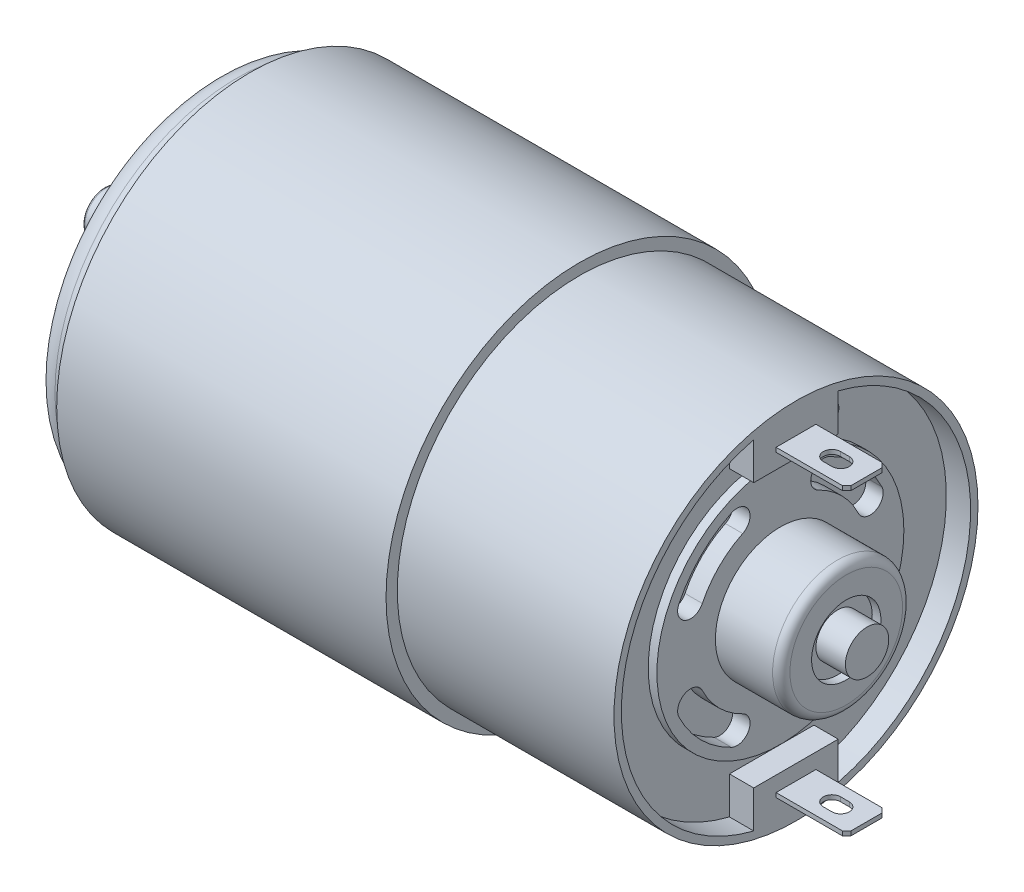
from build123d import *

# Parameters (mm, degrees)
SKETCH1_W                      = 38
SKETCH1_H                      = 22.3
SKETCH2_R                      = 21
BOSS_EXTRUDE1_DEPTH            = 25
SKETCH3_W                      = 4.6
SKETCH3_H                      = 0.5
BOSS_EXTRUDE2_DEPTH            = 8.15
CUT_EXTRUDE1_DEPTH             = 40.8
SKETCH5_W                      = 4.6
SKETCH5_H                      = 0.5
BOSS_EXTRUDE3_DEPTH            = 8.15
CUT_EXTRUDE2_REACH             = 41.8
CUT_EXTRUDE3_DEPTH             = 2.8
SKETCH8_R                      = 14.25
BOSS_EXTRUDE4_DEPTH            = 1
CUT_EXTRUDE4_DEPTH             = 2
CUT_EXTRUDE5_DEPTH             = 2
CUT_EXTRUDE6_DEPTH             = 2
CUT_EXTRUDE7_DEPTH             = 2
SKETCH13_R                     = 21
BOSS_EXTRUDE5_DEPTH            = 4
CUT_EXTRUDE8_DEPTH             = 10
CUT_EXTRUDE9_DEPTH             = 10
CUT_EXTRUDE10_DEPTH            = 10
CUT_EXTRUDE11_DEPTH            = 10
SKETCH18_R                     = 7.5
BOSS_EXTRUDE6_DEPTH            = 7.6
F_8_0_8_DIAMETER_HOLE1_D       = 8
F_8_0_8_DIAMETER_HOLE1_DEPTH   = 1
SKETCH21_R                     = 8.65
BOSS_EXTRUDE7_DEPTH            = 5
M12_CLEARANCE_HOLE1_D          = 13.25
M12_CLEARANCE_HOLE1_DEPTH      = 1
SKETCH25_W                     = 3.4
SKETCH25_H                     = 2.5
F_2_5_2_5_DIAMETER_HOLE1_D     = 2.5
F_2_5_2_5_DIAMETER_HOLE1_DEPTH = 0.1
F_3_3_3_3_DIAMETER_HOLE1_D     = 3.3
F_3_3_3_3_DIAMETER_HOLE1_DEPTH = 11.5
F_3_3_3_3_DIAMETER_HOLE1_TIP   = 0.991420021
CHAMFER1_SIZE                  = 0.5
FILLET1_R                      = 0.25
FILLET2_R                      = 0.75
FILLET3_R                      = 1
FILLET4_R                      = 2.5


with BuildPart() as part:
    # Sketch1 → Revolve1 (revolve)
    with BuildSketch(Plane.XY):
        with Locations((23, 11.15)):
            Rectangle(SKETCH1_W, SKETCH1_H)
    revolve(axis=Axis((4, 0, 0), (1, 0, 0)))

    # Sketch2 → Boss-Extrude1 (add)
    with BuildSketch(Plane(origin=(42, 0, 0), x_dir=(0, 0, -1), z_dir=(1, 0, 0))):
        Circle(SKETCH2_R)
    extrude(amount=BOSS_EXTRUDE1_DEPTH)

    # Sketch3 → Boss-Extrude2 (add)
    with BuildSketch(Plane(origin=(67, 0, 0), x_dir=(0, 0, -1), z_dir=(1, 0, 0))):
        with Locations((0, 17.25)):
            Rectangle(SKETCH3_W, SKETCH3_H)
    extrude(amount=BOSS_EXTRUDE2_DEPTH)

    # Sketch4 → Cut-Extrude1 (cut, through all)
    with BuildSketch(Plane(origin=(0, 17.5, 0), x_dir=(-1, 0, 0), z_dir=(0, 1, 0))):
        with BuildLine():
            Line((-72.15, -1), (-71.15, -1))
            ThreePointArc((-71.15, -1), (-70.15, 0), (-71.15, 1))
            Line((-71.15, 1), (-72.15, 1))
            ThreePointArc((-72.15, 1), (-73.15, 0), (-72.15, -1))
        make_face()
    extrude(amount=-CUT_EXTRUDE1_DEPTH, mode=Mode.SUBTRACT)

    # Sketch5 → Boss-Extrude3 (add)
    with BuildSketch(Plane(origin=(67, 0, 0), x_dir=(0, 0, -1), z_dir=(1, 0, 0))):
        with Locations((0, -17.25)):
            Rectangle(SKETCH5_W, SKETCH5_H)
    extrude(amount=BOSS_EXTRUDE3_DEPTH)

    # Sketch6 → Cut-Extrude2 (cut, up to next)
    with BuildSketch(Plane.XZ.offset(17.5), mode=Mode.PRIVATE) as cut_extrude2_sk1:
        with BuildLine():
            Line((72.15, 1), (71.15, 1))
            ThreePointArc((71.15, 1), (70.15, 0), (71.15, -1))
            Line((71.15, -1), (72.15, -1))
            ThreePointArc((72.15, -1), (73.15, 0), (72.15, 1))
        make_face()
    cut_extrude2_tool1 = extrude(cut_extrude2_sk1.sketch, amount=-CUT_EXTRUDE2_REACH, mode=Mode.PRIVATE) & part.part
    add(cut_extrude2_tool1.solids().sort_by_distance((71.65, -17.5, 0))[0], mode=Mode.SUBTRACT)

    # Sketch7 → Cut-Extrude3 (cut)
    with BuildSketch(Plane(origin=(67, 0, 0), x_dir=(0, 0, -1), z_dir=(1, 0, 0))):
        with BuildLine():
            Line((4.875, 19.551390616), (4.875, 15.25))
            Line((4.875, 15.25), (-4.875, 15.25))
            Line((-4.875, 15.25), (-4.875, 19.551390616))
            ThreePointArc((-4.875, 19.551390616), (-20.15, 0), (-4.875, -19.551390616))
            Line((-4.875, -19.551390616), (-4.875, -15.25))
            Line((-4.875, -15.25), (4.875, -15.25))
            Line((4.875, -15.25), (4.875, -19.551390616))
            ThreePointArc((4.875, -19.551390616), (20.15, 0), (4.875, 19.551390616))
        make_face()
    extrude(amount=-CUT_EXTRUDE3_DEPTH, mode=Mode.SUBTRACT)

    # Sketch8 → Boss-Extrude4 (add)
    with BuildSketch(Plane(origin=(64.2, 0, 0), x_dir=(0, 0, -1), z_dir=(1, 0, 0))):
        Circle(SKETCH8_R)
    extrude(amount=BOSS_EXTRUDE4_DEPTH)

    # Sketch9 → Cut-Extrude4 (cut)
    with BuildSketch(Plane(origin=(65.2, 0, 0), x_dir=(0, 0, -1), z_dir=(1, 0, 0))):
        with BuildLine():
            ThreePointArc((-5.652173913, 11.706960752), (-9.192388155, 9.192388155), (-11.706960752, 5.652173913))
            ThreePointArc((-11.706960752, 5.652173913), (-11.008331502, 3.649196836), (-9.005354425, 4.347826087))
            ThreePointArc((-9.005354425, 4.347826087), (-7.071067812, 7.071067812), (-4.347826087, 9.005354425))
            ThreePointArc((-4.347826087, 9.005354425), (-3.649196836, 11.008331502), (-5.652173913, 11.706960752))
        make_face()
    extrude(amount=-CUT_EXTRUDE4_DEPTH, mode=Mode.SUBTRACT)

    # Sketch10 → Cut-Extrude5 (cut)
    with BuildSketch(Plane(origin=(65.2, 0, 0), x_dir=(0, 0, -1), z_dir=(1, 0, 0))):
        with BuildLine():
            ThreePointArc((11.706960752, 5.652173913), (9.192388155, 9.192388155), (5.652173913, 11.706960752))
            ThreePointArc((5.652173913, 11.706960752), (3.649196836, 11.008331502), (4.347826087, 9.005354425))
            ThreePointArc((4.347826087, 9.005354425), (7.071067812, 7.071067812), (9.005354425, 4.347826087))
            ThreePointArc((9.005354425, 4.347826087), (11.008331502, 3.649196836), (11.706960752, 5.652173913))
        make_face()
    extrude(amount=-CUT_EXTRUDE5_DEPTH, mode=Mode.SUBTRACT)

    # Sketch11 → Cut-Extrude6 (cut)
    with BuildSketch(Plane(origin=(65.2, 0, 0), x_dir=(0, 0, -1), z_dir=(1, 0, 0))):
        with BuildLine():
            ThreePointArc((5.652173913, -11.706960752), (9.192388155, -9.192388155), (11.706960752, -5.652173913))
            ThreePointArc((11.706960752, -5.652173913), (11.008331502, -3.649196836), (9.005354425, -4.347826087))
            ThreePointArc((9.005354425, -4.347826087), (7.071067812, -7.071067812), (4.347826087, -9.005354425))
            ThreePointArc((4.347826087, -9.005354425), (3.649196836, -11.008331502), (5.652173913, -11.706960752))
        make_face()
    extrude(amount=-CUT_EXTRUDE6_DEPTH, mode=Mode.SUBTRACT)

    # Sketch12 → Cut-Extrude7 (cut)
    with BuildSketch(Plane(origin=(65.2, 0, 0), x_dir=(0, 0, -1), z_dir=(1, 0, 0))):
        with BuildLine():
            ThreePointArc((-11.706960752, -5.652173913), (-9.192388155, -9.192388155), (-5.652173913, -11.706960752))
            ThreePointArc((-5.652173913, -11.706960752), (-3.649196836, -11.008331502), (-4.347826087, -9.005354425))
            ThreePointArc((-4.347826087, -9.005354425), (-7.071067812, -7.071067812), (-9.005354425, -4.347826087))
            ThreePointArc((-9.005354425, -4.347826087), (-11.008331502, -3.649196836), (-11.706960752, -5.652173913))
        make_face()
    extrude(amount=-CUT_EXTRUDE7_DEPTH, mode=Mode.SUBTRACT)

    # Sketch13 → Boss-Extrude5 (add)
    with BuildSketch(Plane.ZY.offset(-4)):
        Circle(SKETCH13_R)
    extrude(amount=BOSS_EXTRUDE5_DEPTH)

    # Sketch14 → Cut-Extrude8 (cut)
    with BuildSketch(Plane.ZY):
        with BuildLine():
            Line((6.761892188, 14.500924593), (4.775586358, 10.241277994))
            ThreePointArc((4.775586358, 10.241277994), (7.990306627, 7.990306627), (10.241277994, 4.775586358))
            Line((10.241277994, 4.775586358), (14.500924593, 6.761892188))
            ThreePointArc((14.500924593, 6.761892188), (11.313708499, 11.313708499), (6.761892188, 14.500924593))
        make_face()
    extrude(amount=-CUT_EXTRUDE8_DEPTH, mode=Mode.SUBTRACT)

    # Sketch15 → Cut-Extrude9 (cut)
    with BuildSketch(Plane.ZY):
        with BuildLine():
            Line((-6.761892188, -14.500924593), (-4.775586358, -10.241277994))
            ThreePointArc((-4.775586358, -10.241277994), (-7.990306627, -7.990306627), (-10.241277994, -4.775586358))
            Line((-10.241277994, -4.775586358), (-14.500924593, -6.761892188))
            ThreePointArc((-14.500924593, -6.761892188), (-11.313708499, -11.313708499), (-6.761892188, -14.500924593))
        make_face()
    extrude(amount=-CUT_EXTRUDE9_DEPTH, mode=Mode.SUBTRACT)

    # Sketch16 → Cut-Extrude10 (cut)
    with BuildSketch(Plane.ZY):
        with BuildLine():
            Line((-14.500924593, 6.761892188), (-10.241277994, 4.775586358))
            ThreePointArc((-10.241277994, 4.775586358), (-7.990306627, 7.990306627), (-4.775586358, 10.241277994))
            Line((-4.775586358, 10.241277994), (-6.761892188, 14.500924593))
            ThreePointArc((-6.761892188, 14.500924593), (-11.313708499, 11.313708499), (-14.500924593, 6.761892188))
        make_face()
    extrude(amount=-CUT_EXTRUDE10_DEPTH, mode=Mode.SUBTRACT)

    # Sketch17 → Cut-Extrude11 (cut)
    with BuildSketch(Plane.ZY):
        with BuildLine():
            Line((14.500924593, -6.761892188), (10.241277994, -4.775586358))
            ThreePointArc((10.241277994, -4.775586358), (7.990306627, -7.990306627), (4.775586358, -10.241277994))
            Line((4.775586358, -10.241277994), (6.761892188, -14.500924593))
            ThreePointArc((6.761892188, -14.500924593), (11.313708499, -11.313708499), (14.500924593, -6.761892188))
        make_face()
    extrude(amount=-CUT_EXTRUDE11_DEPTH, mode=Mode.SUBTRACT)

    # Sketch18 → Boss-Extrude6 (add)
    with BuildSketch(Plane(origin=(65.2, 0, 0), x_dir=(0, 0, -1), z_dir=(1, 0, 0))):
        Circle(SKETCH18_R)
    extrude(amount=BOSS_EXTRUDE6_DEPTH)

    # Ø8.0 (8) Diameter Hole1
    with Locations(Plane(origin=(72.8, 0, 0), x_dir=(0, 0, -1), z_dir=(1, 0, 0))):
        with Locations((0, 0)):
            Hole(F_8_0_8_DIAMETER_HOLE1_D / 2, depth=F_8_0_8_DIAMETER_HOLE1_DEPTH)

    # Sketch21 → Boss-Extrude7 (add)
    with BuildSketch(Plane.ZY):
        Circle(SKETCH21_R)
    extrude(amount=BOSS_EXTRUDE7_DEPTH)

    # M12 Clearance Hole1
    with Locations(Plane.ZY.offset(5)):
        with Locations((0, 0)):
            Hole(M12_CLEARANCE_HOLE1_D / 2, depth=M12_CLEARANCE_HOLE1_DEPTH)

    # Sketch24 → Revolve2 (revolve)
    with BuildSketch(Plane(origin=(0, 0, 0), x_dir=(-1, 0, 0), z_dir=(0, 0, -1))):
        Polygon((4, 3.75), (4, 0), (12.8, 0), (12.8, 2.5), (5, 2.5), (5, 3.75), align=None)
    revolve(axis=Axis((-4, 0, 0), (-1, 0, 0)))

    # Sketch25 → Revolve3 (revolve)
    with BuildSketch(Plane(origin=(0, 0, 0), x_dir=(-1, 0, 0), z_dir=(0, 0, -1))):
        with Locations((-73.5, 1.25)):
            Rectangle(SKETCH25_W, SKETCH25_H)
    revolve(axis=Axis((75.2, 0, 0), (-1, 0, 0)))

    # Ø2.5 (2.5) Diameter Hole1
    with Locations(Plane(origin=(64.2, 0, 0), x_dir=(0, 0, -1), z_dir=(1, 0, 0))):
        with Locations((6.5, 15)):
            Hole(F_2_5_2_5_DIAMETER_HOLE1_D / 2, depth=F_2_5_2_5_DIAMETER_HOLE1_DEPTH)

    # Ø3.3 (3.3) Diameter Hole1
    with Locations(Plane.ZY):
        with Locations((0, 14.5), (0, -14.5)):
            Hole(F_3_3_3_3_DIAMETER_HOLE1_D / 2, depth=F_3_3_3_3_DIAMETER_HOLE1_DEPTH)
            with Locations((0, 0, -(F_3_3_3_3_DIAMETER_HOLE1_DEPTH + F_3_3_3_3_DIAMETER_HOLE1_TIP / 2))):  # 118° drill point
                Cone(0, F_3_3_3_3_DIAMETER_HOLE1_D / 2, F_3_3_3_3_DIAMETER_HOLE1_TIP, mode=Mode.SUBTRACT)

    # Chamfer1
    chamfer1_edges = [part.edges().sort_by_distance(p)[0] for p in [
        (75.15, 17.25, -2.3),
        (75.15, 17.25, 2.3),
        (75.15, -17.25, -2.3),
        (75.15, -17.25, 2.3),
    ]]
    chamfer(chamfer1_edges, length=CHAMFER1_SIZE)

    # Fillet1
    fillet1_edges = [part.edges().sort_by_distance(p)[0] for p in [
        (-12.8, -2.5, 0),
    ]]
    fillet(fillet1_edges, radius=FILLET1_R)

    # Fillet2
    fillet2_edges = [part.edges().sort_by_distance(p)[0] for p in [
        (-5, 0, -8.65),
    ]]
    fillet(fillet2_edges, radius=FILLET2_R)

    # Fillet3
    fillet3_edges = [part.edges().sort_by_distance(p)[0] for p in [
        (72.8, 0, 7.5),
    ]]
    fillet(fillet3_edges, radius=FILLET3_R)

    # Fillet4
    fillet4_edges = [part.edges().sort_by_distance(p)[0] for p in [
        (0, 0, -21),
    ]]
    fillet(fillet4_edges, radius=FILLET4_R)


solid = part.part
